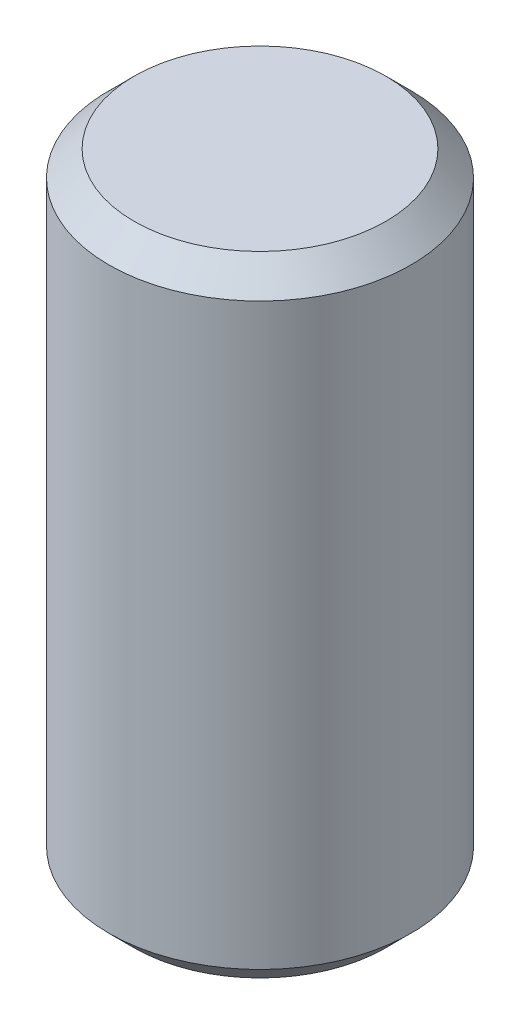
from build123d import *

# Parameters (mm, degrees)
SKETCH1_W     = 3.048
SKETCH1_H     = 12.7
CHAMFER1_SIZE = 0.508


with BuildPart() as part:
    # Sketch1 → Revolve1 (revolve)
    with BuildSketch(Plane.XY):
        with Locations((1.524, 0)):
            Rectangle(SKETCH1_W, SKETCH1_H)
    revolve(axis=Axis((0, 6.080207887, 0), (0, -1, 0)))

    # Chamfer1
    chamfer1_edges = [part.edges().sort_by_distance(p)[0] for p in [
        (-3.048, 6.35, 0),
        (-3.048, -6.35, 0),
    ]]
    chamfer(chamfer1_edges, length=CHAMFER1_SIZE)


solid = part.part
